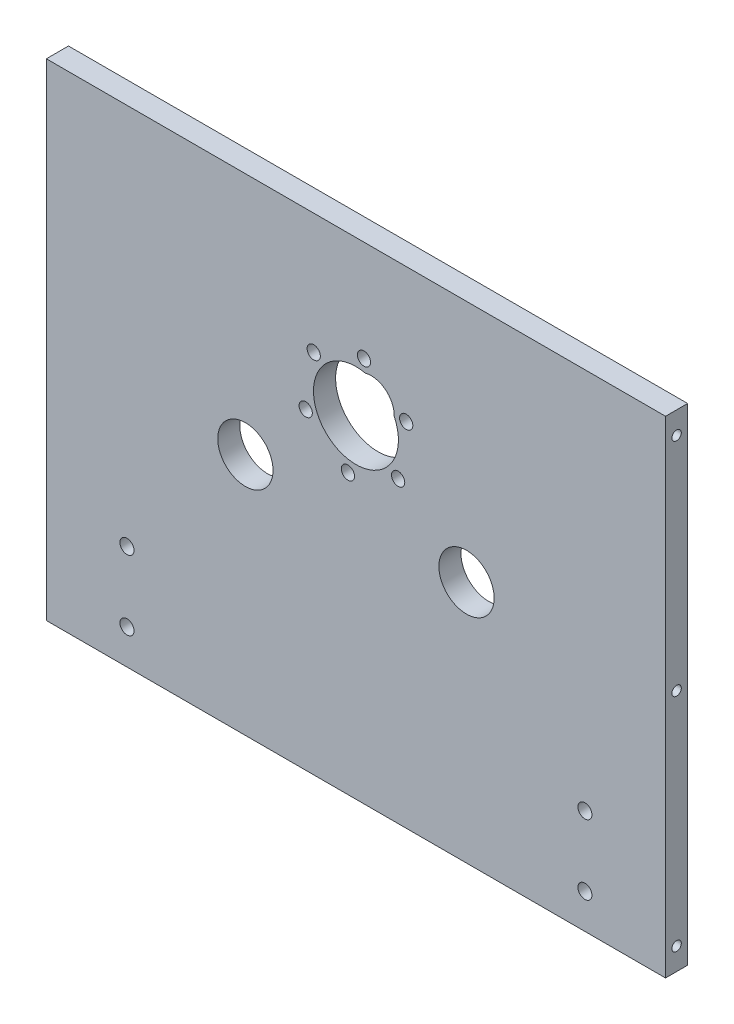
from build123d import *

# Parameters (mm, degrees)
SKETCH1_W                          = 177.8
SKETCH1_H                          = 139.7
BOSS_EXTRUDE1_DEPTH                = 6.35
SKETCH2_R                          = 7.9375
CUT_EXTRUDE1_DEPTH                 = 7.35
TAP_DRILL_FOR_6_32_TAP1_AT_2_COUNT = 2
TAP_DRILL_FOR_6_32_TAP1_AT_2_PITCH = 63.5
TAP_DRILL_FOR_6_32_TAP1_AT_3_COUNT = 2
TAP_DRILL_FOR_6_32_TAP1_AT_3_PITCH = 127
TAP_DRILL_FOR_10_32_TAP1_D         = 4.0386
SKETCH20_R                         = 12.192
CUT_EXTRUDE4_DEPTH                 = 7.35
F_6_CLEARANCE_HOLE1_D              = 3.7973
CIRPATTERN1_COUNT                  = 6
CUT_EXTRUDE5_DEPTH                 = 7.35


with BuildPart() as part:
    # Sketch1 → Boss-Extrude1 (new body)
    with BuildSketch(Plane.XY):
        Rectangle(SKETCH1_W, SKETCH1_H)
    extrude(amount=BOSS_EXTRUDE1_DEPTH)

    # Sketch2 → Cut-Extrude1 (cut, through all)
    with BuildSketch(Plane.XY.offset(6.35)):
        with Locations((-31.75, 0)):
            Circle(SKETCH2_R)
        with Locations((31.75, 0)):
            Circle(SKETCH2_R)
    extrude(amount=-CUT_EXTRUDE1_DEPTH, mode=Mode.SUBTRACT)

    # Sketch17 → Tap Drill for #6-32 Tap1 (revolve, cut)
    with BuildSketch(Plane(origin=(88.9, 63.5, 3.175), x_dir=(0, 0, -1), z_dir=(0, 1, 0))):
        Polygon((0, 0), (0, 13.51269403), (1.35255, 12.7), (1.35255, 0), align=None)
    tap_drill_for_6_32_tap1 = revolve(axis=Axis((95.25, 63.5, 3.175), (-1, 0, 0)), mode=Mode.SUBTRACT)

    # Tap Drill for #6-32 Tap1 at 2: Tap Drill for #6-32 Tap1 ×2
    with Locations(*[(0, -i * TAP_DRILL_FOR_6_32_TAP1_AT_2_PITCH, 0) for i in range(1, TAP_DRILL_FOR_6_32_TAP1_AT_2_COUNT)]):
        add(tap_drill_for_6_32_tap1, mode=Mode.SUBTRACT)

    # Tap Drill for #6-32 Tap1 at 3: Tap Drill for #6-32 Tap1 ×2
    with Locations(*[(0, -i * TAP_DRILL_FOR_6_32_TAP1_AT_3_PITCH, 0) for i in range(1, TAP_DRILL_FOR_6_32_TAP1_AT_3_COUNT)]):
        add(tap_drill_for_6_32_tap1, mode=Mode.SUBTRACT)

    # Mirror2: Tap Drill for #6-32 Tap1 across plane
    add(tap_drill_for_6_32_tap1.mirror(Plane(origin=(0, 0, 0), x_dir=(0, 0, 1), z_dir=(1, 0, 0))), mode=Mode.SUBTRACT)

    # Mirror2 copy 1 sketch → Mirror2 copy 1 (revolve, cut)
    with BuildSketch(Plane(origin=(-88.9, 0, 3.175), x_dir=(0, 0, -1), z_dir=(0, 1, 0))):
        Polygon((0, 0), (0, -13.51269403), (1.35255, -12.7), (1.35255, 0), align=None)
    revolve(axis=Axis((-95.25, 0, 3.175), (-1, 0, 0)), mode=Mode.SUBTRACT)

    # Mirror2 copy 2 sketch → Mirror2 copy 2 (revolve, cut)
    with BuildSketch(Plane(origin=(-88.9, -63.5, 3.175), x_dir=(0, 0, -1), z_dir=(0, 1, 0))):
        Polygon((0, 0), (0, -13.51269403), (1.35255, -12.7), (1.35255, 0), align=None)
    revolve(axis=Axis((-95.25, -63.5, 3.175), (-1, 0, 0)), mode=Mode.SUBTRACT)

    # Tap Drill for #10-32 Tap1 (through all)
    with Locations(Plane.XY.offset(6.35)):
        with Locations((-65.750000072, -59.85), (-65.750000072, -39.85)):
            tap_drill_for_10_32_tap1 = Hole(TAP_DRILL_FOR_10_32_TAP1_D / 2)

    # Mirror3: Tap Drill for #10-32 Tap1 across plane
    add(tap_drill_for_10_32_tap1.mirror(Plane(origin=(0, 0, 0), x_dir=(0, 0, 1), z_dir=(1, 0, 0))), mode=Mode.SUBTRACT)

    # Sketch20 → Cut-Extrude4 (cut, through all)
    with BuildSketch(Plane.XY.offset(6.35)):
        with Locations((0, 25.577056324)):
            Circle(SKETCH20_R)
    extrude(amount=-CUT_EXTRUDE4_DEPTH, mode=Mode.SUBTRACT)

    # #6 Clearance Hole1 (through all)
    with Locations(Plane.XY.offset(6.35)):
        with Locations((2.308510654, 40.904181905)):
            f_6_clearance_hole1 = Hole(F_6_CLEARANCE_HOLE1_D / 2)

    # CirPattern1: #6 Clearance Hole1 ×6 about axis
    cirpattern1_axis = Axis((0, 25.577056324, 0), (0, 0, 1))
    for i in range(1, CIRPATTERN1_COUNT):
        add(f_6_clearance_hole1.rotate(cirpattern1_axis, i * 360 / CIRPATTERN1_COUNT), mode=Mode.SUBTRACT)

    # Sketch23 → Cut-Extrude5 (cut, through all)
    with BuildSketch(Plane(origin=(0, 0, 0), x_dir=(-1, 0, 0), z_dir=(0, 0, -1))):
        with BuildLine():
            ThreePointArc((0.824054314, 35.186643177), (-8.500139633, 36.23824065), (-9.551737105, 26.914046703))
            ThreePointArc((-9.551737105, 26.914046703), (-0.227543158, 25.862449231), (0.824054314, 35.186643177))
        make_face()
    extrude(amount=-CUT_EXTRUDE5_DEPTH, mode=Mode.SUBTRACT)


solid = part.part
